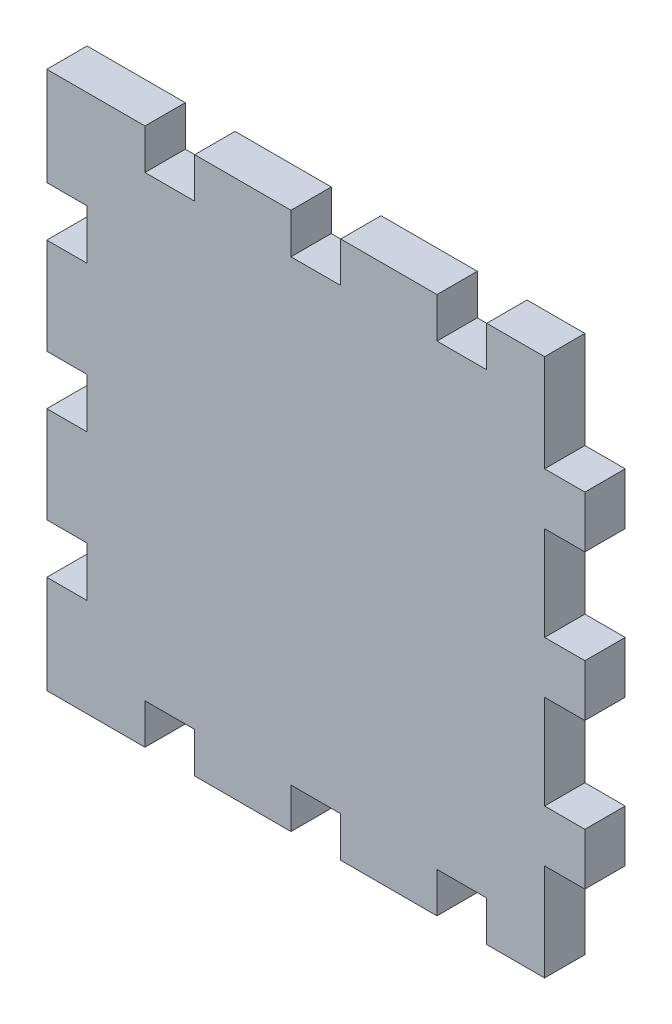
from build123d import *

# Parameters (mm, degrees)
BOSS_EXTRUDE1_DEPTH = 3.175
BOSS_EXTRUDE2_DEPTH = 3.175


with BuildPart() as part:
    # Sketch2 → Boss-Extrude1 (new body)
    with BuildSketch(Plane.XY):
        Polygon((-2, 17.975), (-2, 21.15), (-9.5, 21.15), (-9.5, 17.975), (-13.5, 17.975), (-13.5, 21.15), (-21.15, 21.15), (-21.15, 13.5), (-17.975, 13.5), (-17.975, 9.5), (-21.15, 9.5), (-21.15, 2), (-17.975, 2), (-17.975, -2), (-21.15, -2), (-21.15, -9.5), (-17.975, -9.5), (-17.975, -13.5), (-21.15, -13.5), (-21.15, -21.15), (-13.5, -21.15), (-13.5, -17.975), (-9.5, -17.975), (-9.5, -21.15), (-2, -21.15), (-2, -17.975), (2, -17.975), (2, -21.15), (9.5, -21.15), (9.5, -17.975), (13.5, -17.975), (13.5, -21.15), (17.975, -21.15), (17.975, -13.5), (21.15, -13.5), (21.15, -9.5), (17.975, -9.5), (17.975, -2), (21.15, -2), (21.15, 2), (17.975, 2), (17.975, 9.5), (21.15, 9.5), (21.15, 13.5), (17.975, 13.5), (17.975, 21.15), (13.5, 21.15), (13.5, 17.975), (9.5, 17.975), (9.5, 21.15), (2, 21.15), (2, 17.975), align=None)
    extrude(amount=BOSS_EXTRUDE1_DEPTH)

    # Sketch3 → Boss-Extrude2 (add)
    with BuildSketch(Plane.XY.offset(3.175)):
        Polygon((18.01564, -2.04064), (21.19064, -2.04064), (21.19064, 2.04064), (18.01564, 2.04064), (18.01564, 9.45936), (21.19064, 9.45936), (21.19064, 13.54064), (18.01564, 13.54064), (18.01564, 21.19064), (13.45936, 21.19064), (13.45936, 18.01564), (9.54064, 18.01564), (9.54064, 21.19064), (1.95936, 21.19064), (1.95936, 18.01564), (-1.95936, 18.01564), (-1.95936, 21.19064), (-9.54064, 21.19064), (-9.54064, 18.01564), (-13.45936, 18.01564), (-13.45936, 21.19064), (-21.19064, 21.19064), (-21.19064, 13.45936), (-18.01564, 13.45936), (-18.01564, 9.54064), (-21.19064, 9.54064), (-21.19064, 1.95936), (-18.01564, 1.95936), (-18.01564, -1.95936), (-21.19064, -1.95936), (-21.19064, -9.54064), (-18.01564, -9.54064), (-18.01564, -13.45936), (-21.19064, -13.45936), (-21.19064, -21.19064), (-13.45936, -21.19064), (-13.45936, -18.01564), (-9.54064, -18.01564), (-9.54064, -21.19064), (-1.95936, -21.19064), (-1.95936, -18.01564), (1.95936, -18.01564), (1.95936, -21.19064), (9.54064, -21.19064), (9.54064, -18.01564), (13.45936, -18.01564), (13.45936, -21.19064), (18.01564, -21.19064), (18.01564, -13.54064), (21.19064, -13.54064), (21.19064, -9.45936), (18.01564, -9.45936), align=None)
    extrude(amount=-BOSS_EXTRUDE2_DEPTH)


solid = part.part
